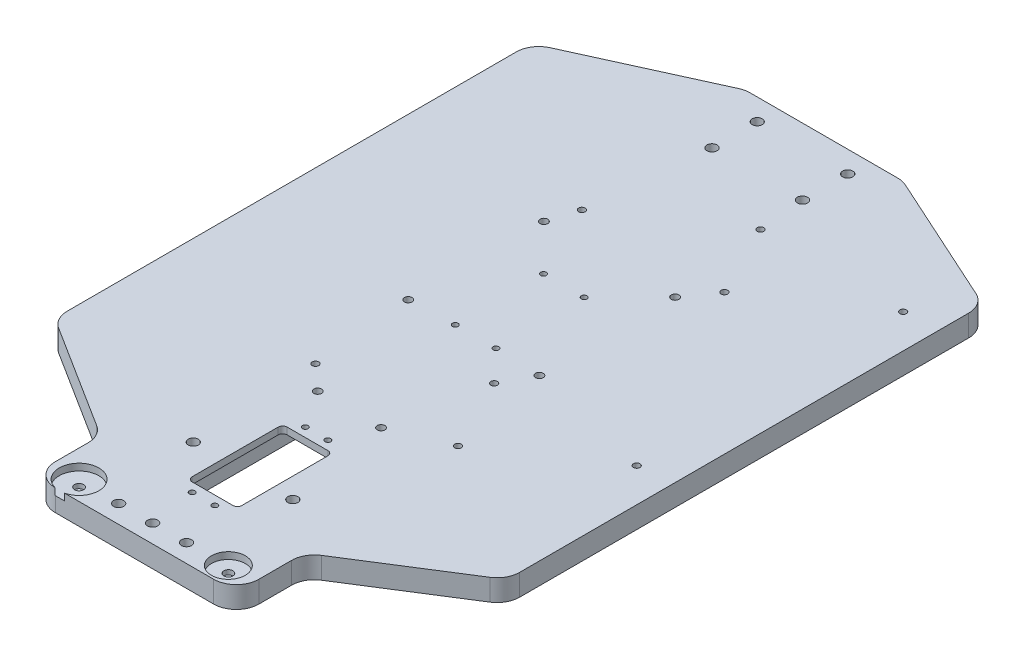
from build123d import *

# Parameters (mm, degrees)
CHASSIS_BASE_SHAPE_DEPTH        = 9.525
M4_CLEARANCE_HOLE1_D            = 4.5
M4_CLEARANCE_HOLE2_D            = 4.5
FILLET1_R                       = 10
SERVO_RECESS_DEPTH              = 6.525
SERVO_CUTOUT_DEPTH              = 4
M3X0_5_SERVO_D                  = 2.5
M2_5_CLEARANCE_ESC_D            = 2.9
M2_5X0_45_TAP_FOR_RPI_D         = 2.05
M2_5X0_45_TAP_FOR_RPI_DEPTH     = 5
M2_5X0_45_TAP_FOR_RPI_TIP       = 0.615882135
SKETCH27_R                      = 8.75
SKETCH27_R_2                    = 7.5
BELLCRANK_POSITIONS_DEPTH       = 3
SKETCH28_R                      = 2
DOWEL_SCREW_CAP_SLOTS_DEPTH     = 2
BATTERY_HOLES_D                 = 3.4
TAP_DRILL_FOR_M3X0_5_TAP1_D     = 2.5
TAP_DRILL_FOR_M3X0_5_TAP1_DEPTH = 9.525


with BuildPart() as part:
    # Sketch2 → Chassis Base Shape (new body)
    with BuildSketch(Plane(origin=(0, 0, 0), x_dir=(1, 0, 0), z_dir=(0, 1, 0))):
        Polygon((-100, -85.226624744), (-45, -120), (-45, -150), (0, -150), (0, 0), (0, 154.8), (-34.83712014, 154.8), (-100, 125.194694643), align=None)
    chassis_base_shape = extrude(amount=CHASSIS_BASE_SHAPE_DEPTH)

    # M4 Clearance Hole1 (through all)
    with Locations(Plane(origin=(0, 0, 0), x_dir=(-1, 0, 0), z_dir=(0, -1, 0))):
        with Locations((15, -142), (0, -142), (22, -102)):
            m4_clearance_hole1 = Hole(M4_CLEARANCE_HOLE1_D / 2)

    # M4 Clearance Hole2 (through all)
    with Locations(Plane(origin=(0, 0, 0), x_dir=(-1, 0, 0), z_dir=(0, -1, 0))):
        with Locations((20, 125.3), (20, 145.3)):
            m4_clearance_hole2 = Hole(M4_CLEARANCE_HOLE2_D / 2)

    # Chassis Base Mirror: Chassis Base Shape, M4 Clearance Hole1, M4 Clearance Hole2 across Right Plane
    add(chassis_base_shape.mirror(Plane(origin=(0, 0, 0), x_dir=(0, 0, -1), z_dir=(1, 0, 0))))
    add(m4_clearance_hole1.mirror(Plane(origin=(0, 0, 0), x_dir=(0, 0, -1), z_dir=(1, 0, 0))), mode=Mode.SUBTRACT)
    add(m4_clearance_hole2.mirror(Plane(origin=(0, 0, 0), x_dir=(0, 0, -1), z_dir=(1, 0, 0))), mode=Mode.SUBTRACT)

    # Fillet1
    fillet1_edges = [part.edges().sort_by_distance(p)[0] for p in [
        (-100, 4.7625, -125.194694643),
        (-34.83712014, 4.7625, -154.8),
        (-45, 4.7625, 150),
        (-45, 4.7625, 120),
        (-100, 4.7625, 85.226624744),
        (100, 4.7625, 85.226624744),
        (100, 4.7625, -125.194694643),
        (34.83712014, 4.7625, -154.8),
        (45, 4.7625, 150),
        (45, 4.7625, 120),
    ]]
    fillet(fillet1_edges, radius=FILLET1_R)

    # Sketch7 → Servo Recess (cut)
    with BuildSketch(Plane(origin=(0, 0, 0), x_dir=(-1, 0, 0), z_dir=(0, -1, 0))):
        with BuildLine():
            Line((-12, -126), (8, -126))
            ThreePointArc((8, -126), (9.414213562, -125.414213562), (10, -124))
            Line((10, -124), (10, -69))
            ThreePointArc((10, -69), (9.414213562, -67.585786438), (8, -67))
            Line((8, -67), (-12, -67))
            ThreePointArc((-12, -67), (-13.414213562, -67.585786438), (-14, -69))
            Line((-14, -69), (-14, -124))
            ThreePointArc((-14, -124), (-13.414213562, -125.414213562), (-12, -126))
        make_face()
    extrude(amount=-SERVO_RECESS_DEPTH, mode=Mode.SUBTRACT)

    # Sketch8 → Servo Cutout (cut, through all)
    with BuildSketch(Plane.XZ.offset(-6.525)):
        with BuildLine():
            Line((-7, 117.5), (11, 117.5))
            ThreePointArc((11, 117.5), (12.414213562, 116.914213562), (13, 115.5))
            Line((13, 115.5), (13, 77.5))
            ThreePointArc((13, 77.5), (12.414213562, 76.085786438), (11, 75.5))
            Line((11, 75.5), (-7, 75.5))
            ThreePointArc((-7, 75.5), (-8.414213562, 76.085786438), (-9, 77.5))
            Line((-9, 77.5), (-9, 115.5))
            ThreePointArc((-9, 115.5), (-8.414213562, 116.914213562), (-7, 117.5))
        make_face()
    extrude(amount=-SERVO_CUTOUT_DEPTH, mode=Mode.SUBTRACT)

    # M3x0.5 Servo (through all)
    with Locations(Plane(origin=(0, 6.525, 0), x_dir=(-1, 0, 0), z_dir=(0, -1, 0))):
        with Locations((3, -71.5), (-7, -71.5), (3, -121.5), (-7, -121.5)):
            Hole(M3X0_5_SERVO_D / 2)

    # M2.5 Clearance ESC (through all)
    with Locations(Plane(origin=(0, 0, 0), x_dir=(-1, 0, 0), z_dir=(0, -1, 0))):
        with Locations((25, 72.8), (-85, -13), (25, -45), (-22, -13), (-22, 104.8), (-38, -45), (-85, 104.8), (-38, 72.8)):
            Hole(M2_5_CLEARANCE_ESC_D / 2)

    # M2.5x0.45 Tap for RPi
    with Locations(Plane(origin=(0, 0, 0), x_dir=(-1, 0, 0), z_dir=(0, -1, 0))):
        with Locations((90, -13.2), (41, -13.2), (41, 44.8), (90, 44.8)):
            Hole(M2_5X0_45_TAP_FOR_RPI_D / 2, depth=M2_5X0_45_TAP_FOR_RPI_DEPTH)
            with Locations((0, 0, -(M2_5X0_45_TAP_FOR_RPI_DEPTH + M2_5X0_45_TAP_FOR_RPI_TIP / 2))):  # 118° drill point
                Cone(0, M2_5X0_45_TAP_FOR_RPI_D / 2, M2_5X0_45_TAP_FOR_RPI_TIP, mode=Mode.SUBTRACT)

    # Sketch27 → Bellcrank Positions (cut)
    with BuildSketch(Plane(origin=(0, 9.525, 0), x_dir=(1, 0, 0), z_dir=(0, 1, 0))):
        with Locations((-33, -141.5)):
            Circle(SKETCH27_R)
        with Locations((33, -141.5)):
            Circle(SKETCH27_R_2)
    extrude(amount=-BELLCRANK_POSITIONS_DEPTH, mode=Mode.SUBTRACT)

    # Sketch28 → Dowel Screw Cap Slots (cut)
    with BuildSketch(Plane(origin=(0, 6.525, 0), x_dir=(1, 0, 0), z_dir=(0, 1, 0))):
        with Locations((-33, -141.5)):
            Circle(SKETCH28_R)
        with Locations((33, -141.5)):
            Circle(SKETCH28_R)
    extrude(amount=-DOWEL_SCREW_CAP_SLOTS_DEPTH, mode=Mode.SUBTRACT)

    # Battery Holes (through all)
    with Locations(Plane(origin=(0, 9.525, 0), x_dir=(1, 0, 0), z_dir=(0, 1, 0))):
        with Locations((-14, -55), (-29, 0), (-29, 60), (29, 60), (29, 0), (14, -55)):
            Hole(BATTERY_HOLES_D / 2)

    # Tap Drill for M3x0.5 Tap1
    with Locations(Plane(origin=(0, 0, 0), x_dir=(-1, 0, 0), z_dir=(0, -1, 0))):
        with Locations((9, 0.8), (-9, 0.8), (9, 39.8), (-9, 39.8)):
            Hole(TAP_DRILL_FOR_M3X0_5_TAP1_D / 2, depth=TAP_DRILL_FOR_M3X0_5_TAP1_DEPTH)


solid = part.part
